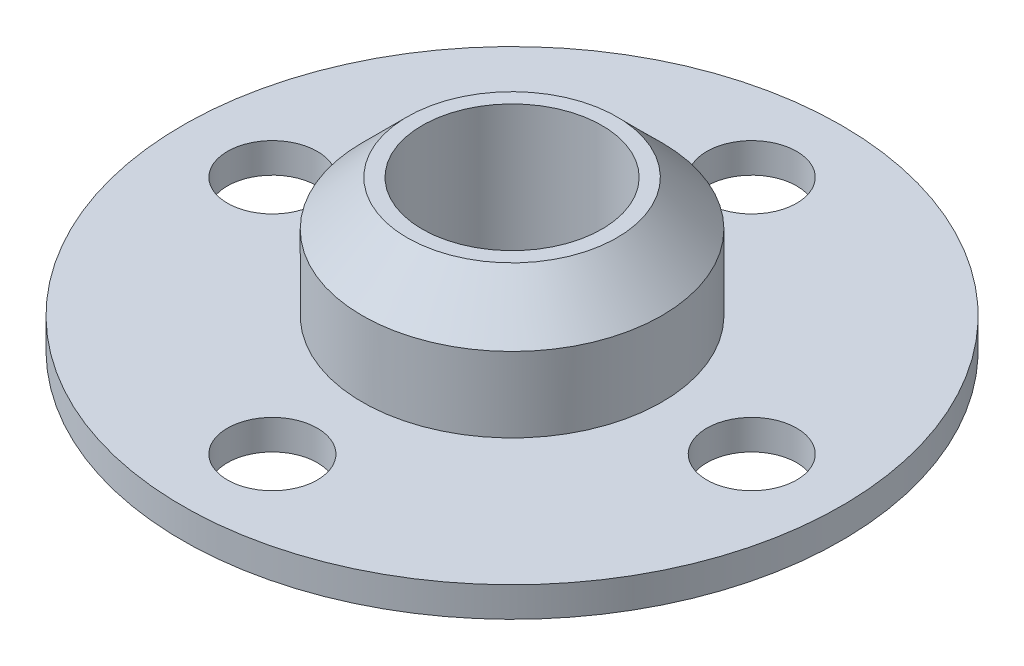
from build123d import *

# Parameters (mm, degrees)
SKETCH1_R           = 5
SKETCH1_R_2         = 3
BOSS_EXTRUDE1_DEPTH = 5
CHAMFER1_SIZE       = 1.5
SKETCH2_R           = 11
SKETCH2_R_2         = 5
SKETCH2_R_3         = 1.5
BOSS_EXTRUDE2_DEPTH = 1


with BuildPart() as part:
    # Sketch1 → Boss-Extrude1 (new body)
    with BuildSketch(Plane(origin=(0, 0, 0), x_dir=(1, 0, 0), z_dir=(0, 1, 0))):
        Circle(SKETCH1_R)
        Circle(SKETCH1_R_2, mode=Mode.SUBTRACT)
    extrude(amount=BOSS_EXTRUDE1_DEPTH)

    # Chamfer1
    chamfer1_edges = [part.edges().sort_by_distance(p)[0] for p in [
        (-5, 5, 0),
    ]]
    chamfer(chamfer1_edges, length=CHAMFER1_SIZE)

    # Sketch2 → Boss-Extrude2 (add)
    with BuildSketch(Plane.XZ):
        Circle(SKETCH2_R)
        Circle(SKETCH2_R_2, mode=Mode.SUBTRACT)
        with Locations((0, 8)):
            Circle(SKETCH2_R_3, mode=Mode.SUBTRACT)
        with Locations((-8, 0)):
            Circle(SKETCH2_R_3, mode=Mode.SUBTRACT)
        with Locations((0, -8)):
            Circle(SKETCH2_R_3, mode=Mode.SUBTRACT)
        with Locations((8, 0)):
            Circle(SKETCH2_R_3, mode=Mode.SUBTRACT)
    extrude(amount=-BOSS_EXTRUDE2_DEPTH)


solid = part.part
